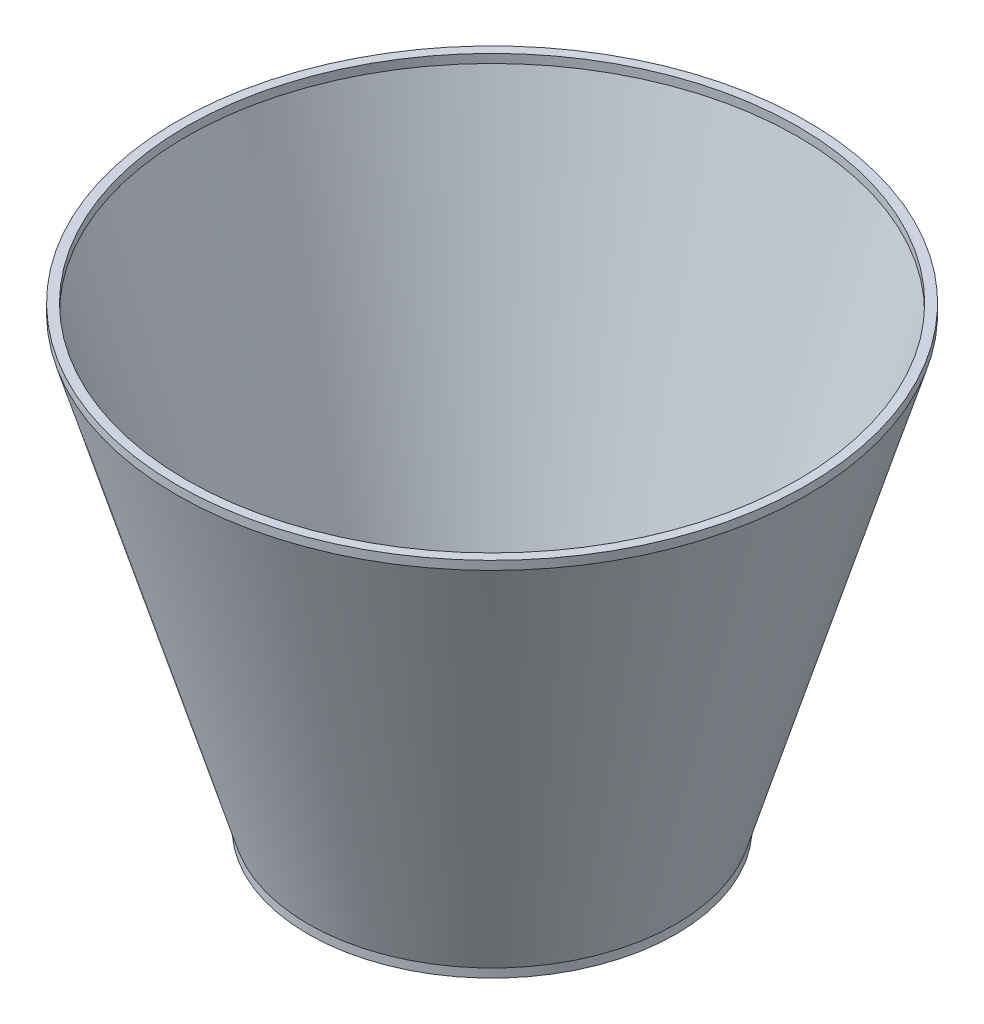
from build123d import *

# Parameters (mm, degrees)
SKETCH2_R           = 42.088061302
SKETCH2_R_2         = 40
BOSS_EXTRUDE1_DEPTH = 2
SKETCH3_R           = 72.088061302
SKETCH3_R_2         = 70
BOSS_EXTRUDE2_DEPTH = 2


with BuildPart() as part:
    # Sketch1 → Revolve1 (revolve)
    with BuildSketch(Plane.XY):
        Polygon((-40, 0), (-70, 100), (-72.088061302, 100), (-42.088061302, 0), align=None)
    revolve(axis=Axis((0, 0, 0), (0, 1, 0)))

    # Sketch2 → Boss-Extrude1 (add)
    with BuildSketch(Plane.XZ):
        Circle(SKETCH2_R)
        Circle(SKETCH2_R_2, mode=Mode.SUBTRACT)
    extrude(amount=BOSS_EXTRUDE1_DEPTH)

    # Sketch3 → Boss-Extrude2 (add)
    with BuildSketch(Plane(origin=(0, 100, 0), x_dir=(1, 0, 0), z_dir=(0, 1, 0))):
        Circle(SKETCH3_R)
        Circle(SKETCH3_R_2, mode=Mode.SUBTRACT)
    extrude(amount=BOSS_EXTRUDE2_DEPTH)


solid = part.part
